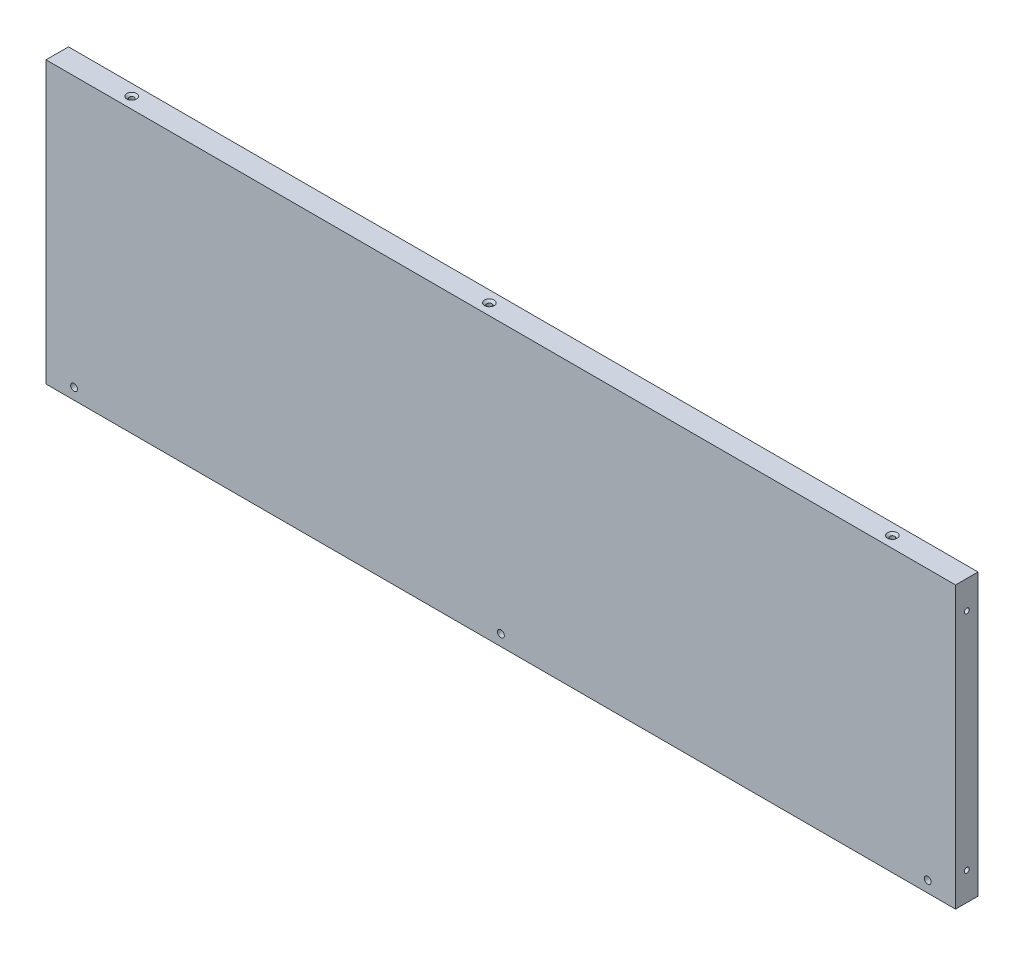
from build123d import *

# Parameters (mm, degrees)
SKETCH1_W                                      = 324
SKETCH1_H                                      = 100
BOSS_EXTRUDE1_DEPTH                            = 8
CBORE_FOR_2_SOCKET_HEAD_CAP_SCREW1_D           = 2.4384
CBORE_FOR_2_SOCKET_HEAD_CAP_SCREW1_CBORE_D     = 4.7625
CBORE_FOR_2_SOCKET_HEAD_CAP_SCREW1_CBORE_DEPTH = 2.1844
F_2_56_TAPPED_HOLE1_D                          = 1.778
F_2_56_TAPPED_HOLE1_DEPTH                      = 15
F_2_56_TAPPED_HOLE1_TIP                        = 0.53416509
F_2_56_TAPPED_HOLE2_D                          = 1.778
F_2_56_TAPPED_HOLE2_DEPTH                      = 15
F_2_56_TAPPED_HOLE2_TIP                        = 0.53416509
SKETCH10_W                                     = 8
SKETCH10_H                                     = 100
CUT_EXTRUDE1_DEPTH                             = 0.1
F_2_56_TAPPED_HOLE3_D                          = 1.778
F_2_56_TAPPED_HOLE3_DEPTH                      = 5.73
F_2_56_TAPPED_HOLE3_CSINK_D                    = 3.4544
F_2_56_TAPPED_HOLE3_CSINK_ANGLE                = 100
F_2_56_TAPPED_HOLE3_TIP                        = 0.53416509


with BuildPart() as part:
    # Sketch1 → Boss-Extrude1 (new body)
    with BuildSketch(Plane.XY):
        with Locations((162, 50)):
            Rectangle(SKETCH1_W, SKETCH1_H)
    extrude(amount=BOSS_EXTRUDE1_DEPTH)

    # CBORE for #2 Socket Head Cap Screw1 (through all)
    with Locations(Plane(origin=(0, 0, 0), x_dir=(-1, 0, 0), z_dir=(0, 0, -1))):
        with Locations((-314, 4), (-10, 4), (-162, 4)):
            CounterBoreHole(CBORE_FOR_2_SOCKET_HEAD_CAP_SCREW1_D / 2, CBORE_FOR_2_SOCKET_HEAD_CAP_SCREW1_CBORE_D / 2, CBORE_FOR_2_SOCKET_HEAD_CAP_SCREW1_CBORE_DEPTH)

    # #2-56 Tapped Hole1
    with Locations(Plane(origin=(324, 0, 0), x_dir=(0, 0, -1), z_dir=(1, 0, 0))):
        with Locations((-4, 90), (-4, 10)):
            Hole(F_2_56_TAPPED_HOLE1_D / 2, depth=F_2_56_TAPPED_HOLE1_DEPTH)
            with Locations((0, 0, -(F_2_56_TAPPED_HOLE1_DEPTH + F_2_56_TAPPED_HOLE1_TIP / 2))):  # 118° drill point
                Cone(0, F_2_56_TAPPED_HOLE1_D / 2, F_2_56_TAPPED_HOLE1_TIP, mode=Mode.SUBTRACT)

    # #2-56 Tapped Hole2
    with Locations(Plane.ZY):
        with Locations((4, 90), (4, 10)):
            Hole(F_2_56_TAPPED_HOLE2_D / 2, depth=F_2_56_TAPPED_HOLE2_DEPTH)
            with Locations((0, 0, -(F_2_56_TAPPED_HOLE2_DEPTH + F_2_56_TAPPED_HOLE2_TIP / 2))):  # 118° drill point
                Cone(0, F_2_56_TAPPED_HOLE2_D / 2, F_2_56_TAPPED_HOLE2_TIP, mode=Mode.SUBTRACT)

    # Sketch10 → Cut-Extrude1 (cut)
    with BuildSketch(Plane(origin=(324, 0, 0), x_dir=(0, 0, -1), z_dir=(1, 0, 0))):
        with Locations((-4, 50)):
            Rectangle(SKETCH10_W, SKETCH10_H)
    extrude(amount=-CUT_EXTRUDE1_DEPTH, mode=Mode.SUBTRACT)

    # #2-56 Tapped Hole3
    with Locations(Plane(origin=(0, 100, 0), x_dir=(1, 0, 0), z_dir=(0, 1, 0))):
        with Locations((297.4, -4), (153.9, -4), (26.5, -4)):
            CounterSinkHole(F_2_56_TAPPED_HOLE3_D / 2, F_2_56_TAPPED_HOLE3_CSINK_D / 2, depth=F_2_56_TAPPED_HOLE3_DEPTH, counter_sink_angle=F_2_56_TAPPED_HOLE3_CSINK_ANGLE)
            with Locations((0, 0, -(F_2_56_TAPPED_HOLE3_DEPTH + F_2_56_TAPPED_HOLE3_TIP / 2))):  # 118° drill point
                Cone(0, F_2_56_TAPPED_HOLE3_D / 2, F_2_56_TAPPED_HOLE3_TIP, mode=Mode.SUBTRACT)


solid = part.part
